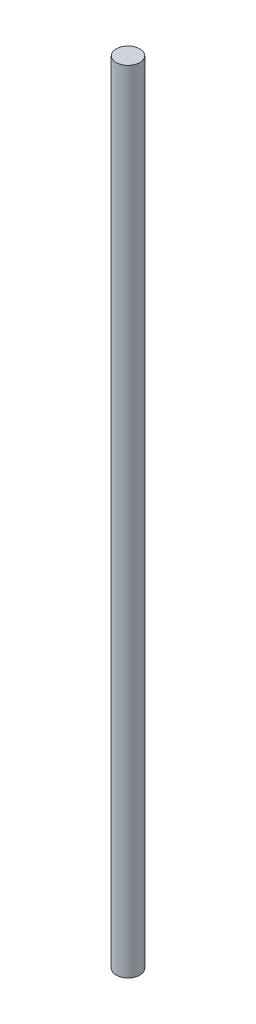
from build123d import *

# Parameters (mm, degrees)
ESQUISSE1_R        = 1.5
BOSS_EXTRU_1_DEPTH = 100


with BuildPart() as part:
    # Esquisse1 → Boss.-Extru.1 (new body)
    with BuildSketch(Plane(origin=(0, 0, 0), x_dir=(1, 0, 0), z_dir=(0, 1, 0))):
        Circle(ESQUISSE1_R)
    extrude(amount=BOSS_EXTRU_1_DEPTH)


solid = part.part
